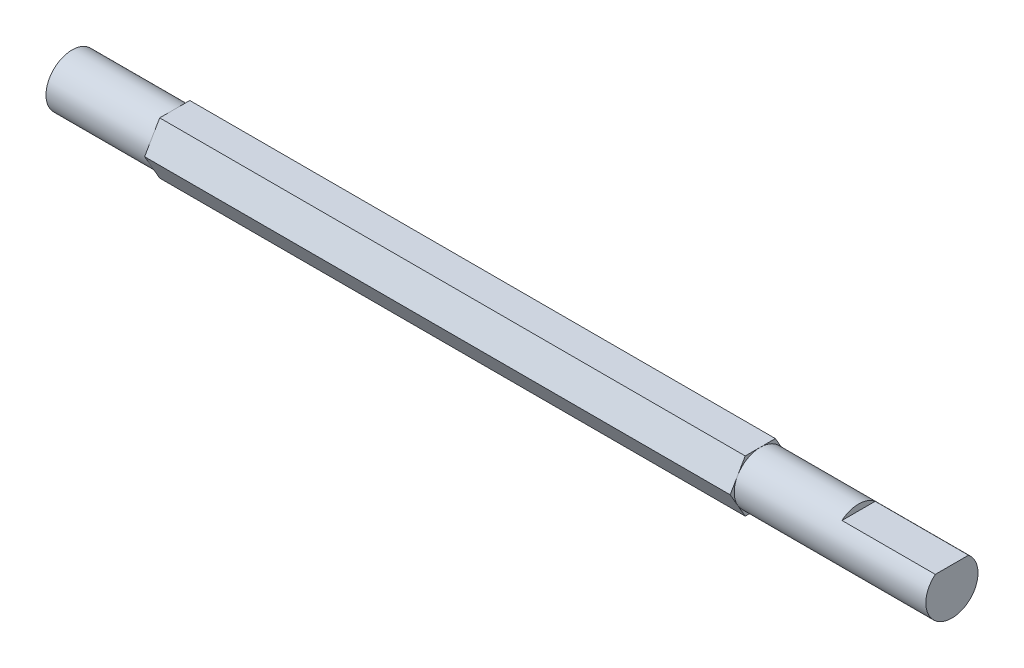
from build123d import *

# Parameters (mm, degrees)
SKIZZE1_R                       = 2.795
AUFSATZ_LINEAR_AUSTRAGEN1_DEPTH = 94.27
AUFSATZ_LINEAR_AUSTRAGEN2_DEPTH = 62.74
SCHNITT_LINEAR_START            = 94.27
SCHNITT_LINEAR_AUSTRAGEN1_DEPTH = 10


with BuildPart() as part:
    # Skizze1 → Aufsatz-Linear austragen1 (new body)
    with BuildSketch(Plane(origin=(0, 0, 0), x_dir=(0, 0, -1), z_dir=(1, 0, 0))):
        Circle(SKIZZE1_R)
    extrude(amount=AUFSATZ_LINEAR_AUSTRAGEN1_DEPTH)

    # Skizze2 → Aufsatz-Linear austragen2 (add)
    with BuildSketch(Plane(origin=(11, 0, 0), x_dir=(0, 0, -1), z_dir=(1, 0, 0))):
        Polygon((1.613694002, 2.795), (-1.613694002, 2.795), (-3.227388005, 0), (-1.613694002, -2.795), (1.613694002, -2.795), (3.227388005, 0), align=None)
    extrude(amount=AUFSATZ_LINEAR_AUSTRAGEN2_DEPTH)

    # Skizze3 → Schnitt-Linear austragen1 (cut)
    with BuildSketch(Plane(origin=(0, 0, 0), x_dir=(0, 0, -1), z_dir=(1, 0, 0)).offset(SCHNITT_LINEAR_START)):
        with BuildLine():
            Line((1.779887637, 2.155), (-1.779887637, 2.155))
            ThreePointArc((-1.779887637, 2.155), (0, 2.795), (1.779887637, 2.155))
        make_face()
    extrude(amount=-SCHNITT_LINEAR_AUSTRAGEN1_DEPTH, mode=Mode.SUBTRACT)


solid = part.part
